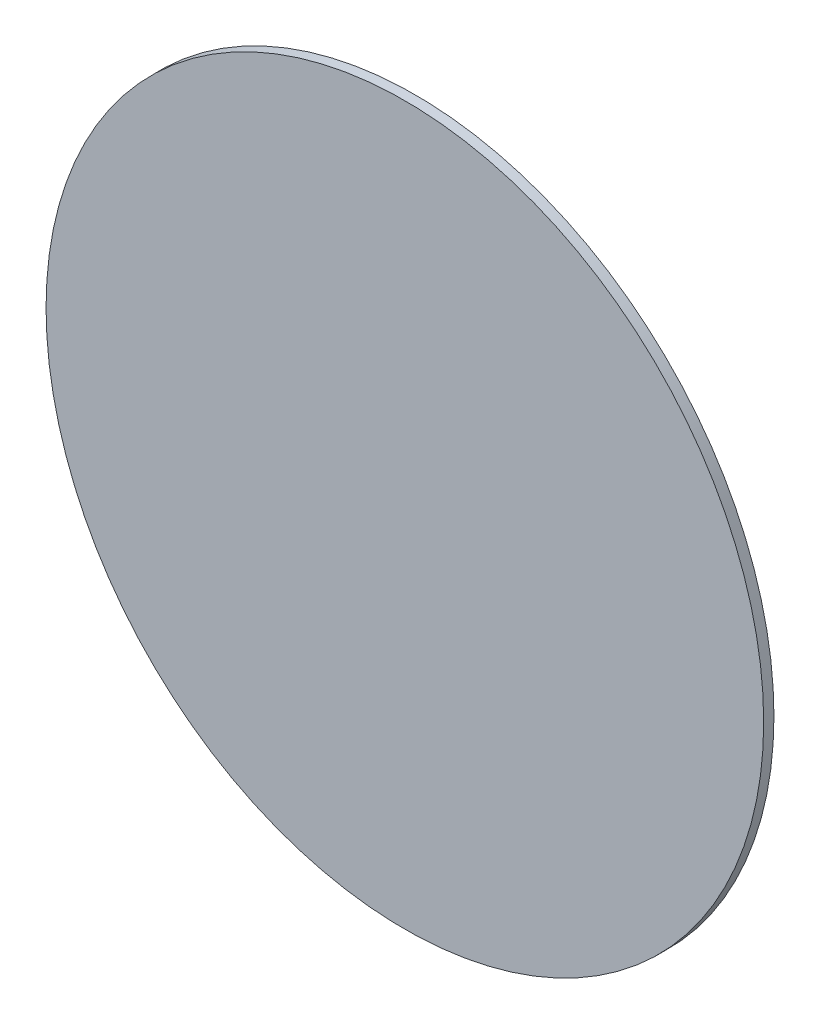
from build123d import *

# Parameters (mm, degrees)
SKETCH3_R           = 70
BOSS_EXTRUDE1_DEPTH = 2


with BuildPart() as part:
    # Sketch3 → Boss-Extrude1 (new body)
    with BuildSketch(Plane.XY.offset(80)):
        Circle(SKETCH3_R)
    extrude(amount=BOSS_EXTRUDE1_DEPTH)


solid = part.part
